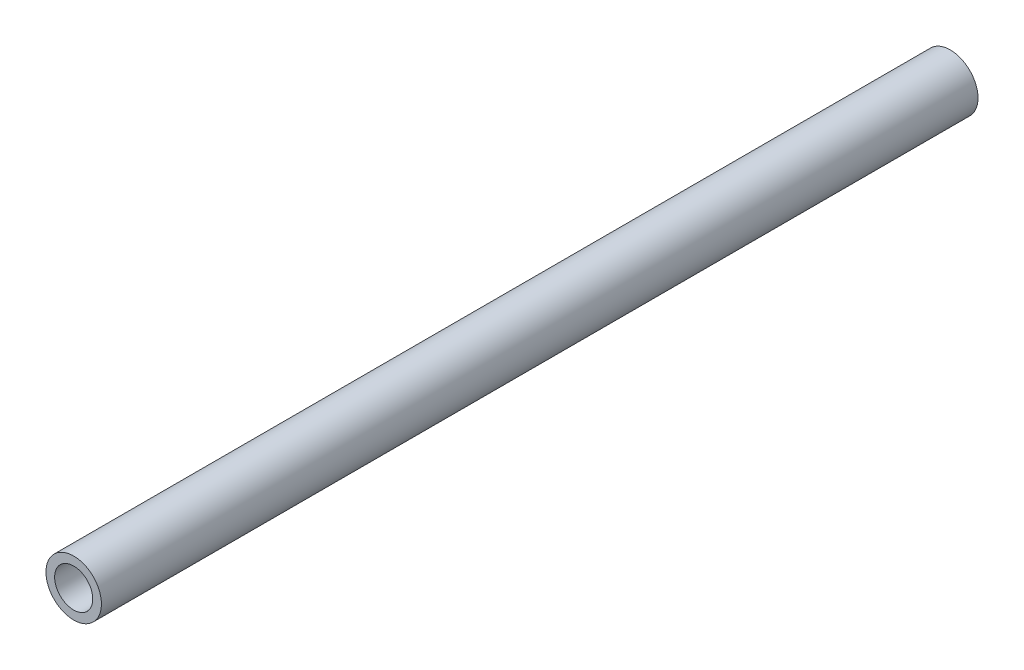
from build123d import *

# Parameters (mm, degrees)
SKETCH1_R           = 12.7
SKETCH1_R_2         = 8.73125
BOSS_EXTRUDE1_DEPTH = 401.32


with BuildPart() as part:
    # Sketch1 → Boss-Extrude1 (new body)
    with BuildSketch(Plane.XY):
        Circle(SKETCH1_R)
        Circle(SKETCH1_R_2, mode=Mode.SUBTRACT)
    extrude(amount=-BOSS_EXTRUDE1_DEPTH)


solid = part.part
